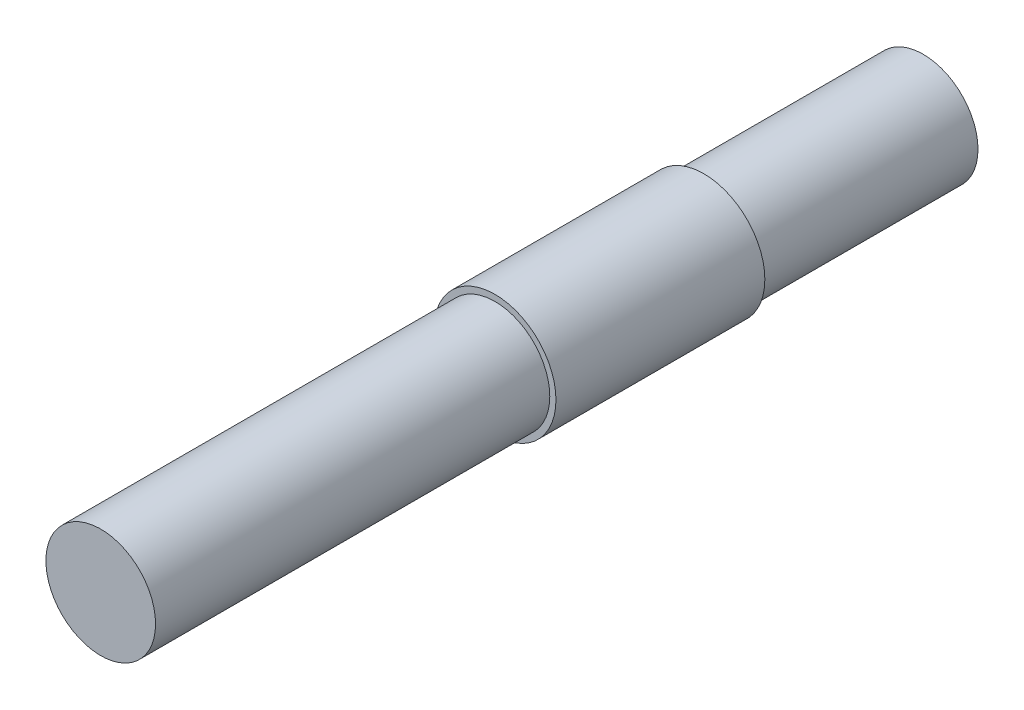
from build123d import *

# Parameters (mm, degrees)
SKETCH1_R           = 5.5626
BOSS_EXTRUDE1_DEPTH = 75
SKETCH5_R           = 5.5626
SKETCH5_R_2         = 5
CUT_EXTRUDE2_DEPTH  = 20
SKETCH6_R           = 5.5626
SKETCH6_R_2         = 5
CUT_EXTRUDE3_DEPTH  = 35.95


with BuildPart() as part:
    # Sketch1 → Boss-Extrude1 (new body)
    with BuildSketch(Plane.XY):
        Circle(SKETCH1_R)
    extrude(amount=BOSS_EXTRUDE1_DEPTH)

    # Sketch5 → Cut-Extrude2 (cut)
    with BuildSketch(Plane.XY.offset(20)):
        Circle(SKETCH5_R)
        Circle(SKETCH5_R_2, mode=Mode.SUBTRACT)
    extrude(amount=-CUT_EXTRUDE2_DEPTH, mode=Mode.SUBTRACT)

    # Sketch6 → Cut-Extrude3 (cut)
    with BuildSketch(Plane.XY.offset(39.05)):
        Circle(SKETCH6_R)
        Circle(SKETCH6_R_2, mode=Mode.SUBTRACT)
    extrude(amount=CUT_EXTRUDE3_DEPTH, mode=Mode.SUBTRACT)


solid = part.part
